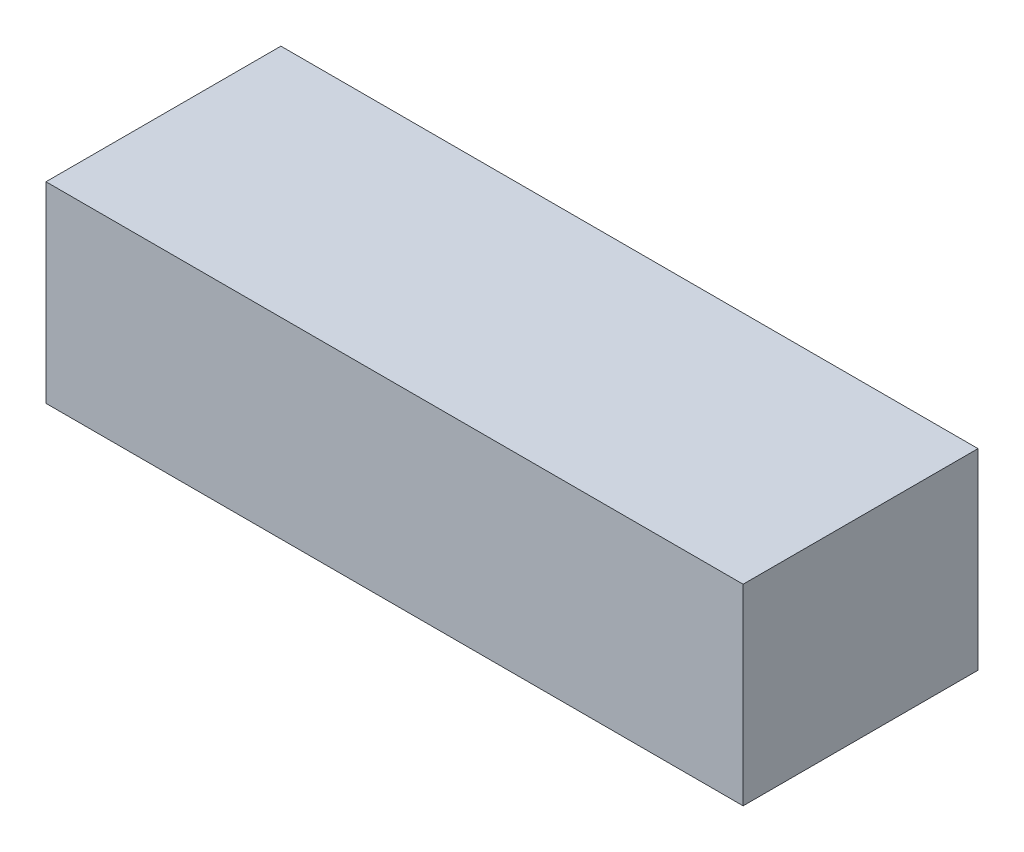
from build123d import *

# Parameters (mm, degrees)
SKIZZE1_W                       = 138
SKIZZE1_H                       = 46.5
AUFSATZ_LINEAR_AUSTRAGEN1_DEPTH = 38


with BuildPart() as part:
    # Skizze1 → Aufsatz-Linear austragen1 (new body)
    with BuildSketch(Plane(origin=(0, 0, 0), x_dir=(1, 0, 0), z_dir=(0, 1, 0))):
        with Locations((0, 23.25)):
            Rectangle(SKIZZE1_W, SKIZZE1_H)
    extrude(amount=AUFSATZ_LINEAR_AUSTRAGEN1_DEPTH)


solid = part.part
